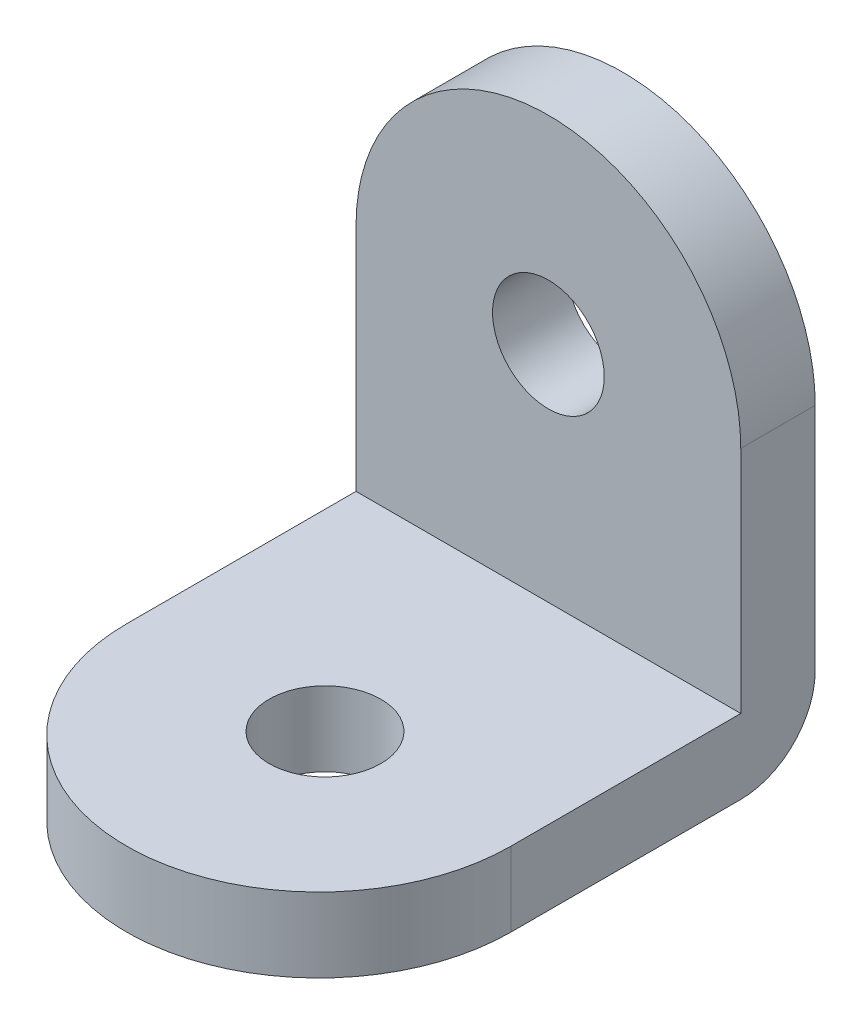
from build123d import *

# Parameters (mm, degrees)
SKETCH1_R           = 2.25
BOSS_EXTRUDE1_DEPTH = 3
CIRPATTERN1_COUNT   = 2
CIRPATTERN1_ANGLE   = 90
FILLET1_R           = 3


with BuildPart() as part:
    # Sketch1 → Boss-Extrude1 (new body)
    with BuildSketch(Plane.XY):
        with BuildLine():
            Line((-7.75, 6.125), (-7.75, -6.125))
            Line((-7.75, -6.125), (7.75, -6.125))
            Line((7.75, -6.125), (7.75, 6.125))
            ThreePointArc((7.75, 6.125), (0, 13.875), (-7.75, 6.125))
        make_face()
        with Locations((0, 5.875)):
            Circle(SKETCH1_R, mode=Mode.SUBTRACT)
    boss_extrude1 = extrude(amount=BOSS_EXTRUDE1_DEPTH)

    # CirPattern1: Boss-Extrude1 ×2 about axis
    cirpattern1_axis = Axis((-8.525, -4.625, 1.5), (1, 0, 0))
    for i in range(1, CIRPATTERN1_COUNT):
        add(boss_extrude1.rotate(cirpattern1_axis, i * CIRPATTERN1_ANGLE / (CIRPATTERN1_COUNT - 1)))

    # Fillet1
    fillet1_edges = [part.edges().sort_by_distance(p)[0] for p in [
        (0, -6.125, 0),
    ]]
    fillet(fillet1_edges, radius=FILLET1_R)


solid = part.part
